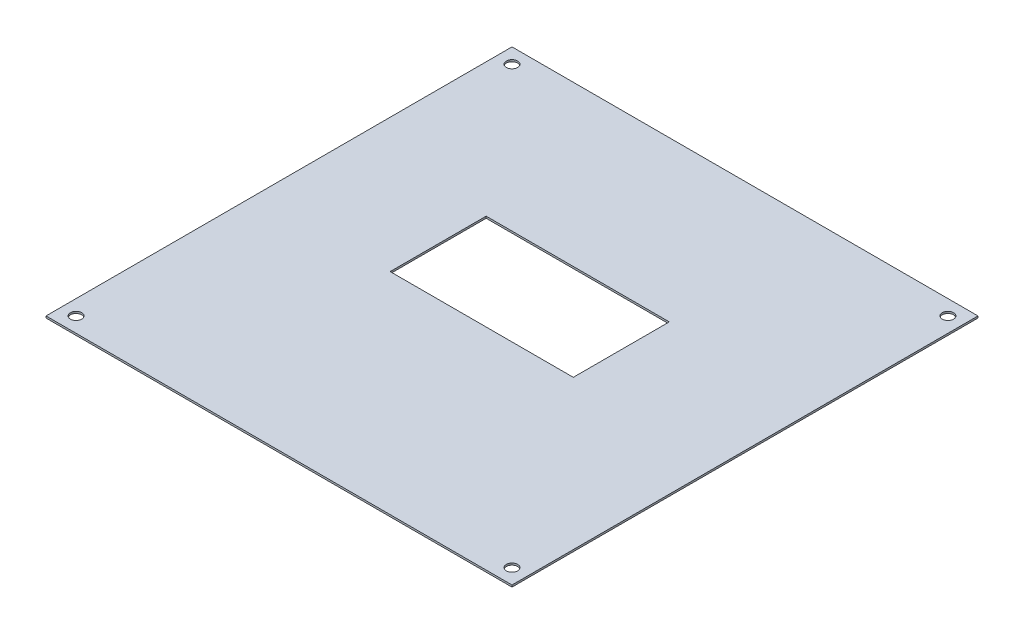
from build123d import *

# Parameters (mm, degrees)
SKETCH_1_W      = 124
SKETCH_1_H      = 124
SKETCH_1_R      = 1.5
SKETCH_1_W_2    = 48.735340729
SKETCH_1_H_2    = 25.546751189
EXTRUDE_1_DEPTH = 0.5


with BuildPart() as part:
    # Эскиз1 → Бобышка-Вытянуть1 (new body)
    with BuildSketch(Plane(origin=(0, 0, 0), x_dir=(1, 0, 0), z_dir=(0, 1, 0))):
        with Locations((62, 62)):
            Rectangle(SKETCH_1_W, SKETCH_1_H)
        with Locations((4, 120)):
            Circle(SKETCH_1_R, mode=Mode.SUBTRACT)
        with Locations((120, 120)):
            Circle(SKETCH_1_R, mode=Mode.SUBTRACT)
        with Locations((120, 4)):
            Circle(SKETCH_1_R, mode=Mode.SUBTRACT)
        with Locations((4, 4)):
            Circle(SKETCH_1_R, mode=Mode.SUBTRACT)
        with Locations((59.936608558, 68.779714739)):
            Rectangle(SKETCH_1_W_2, SKETCH_1_H_2, mode=Mode.SUBTRACT)
    extrude(amount=EXTRUDE_1_DEPTH)


solid = part.part
